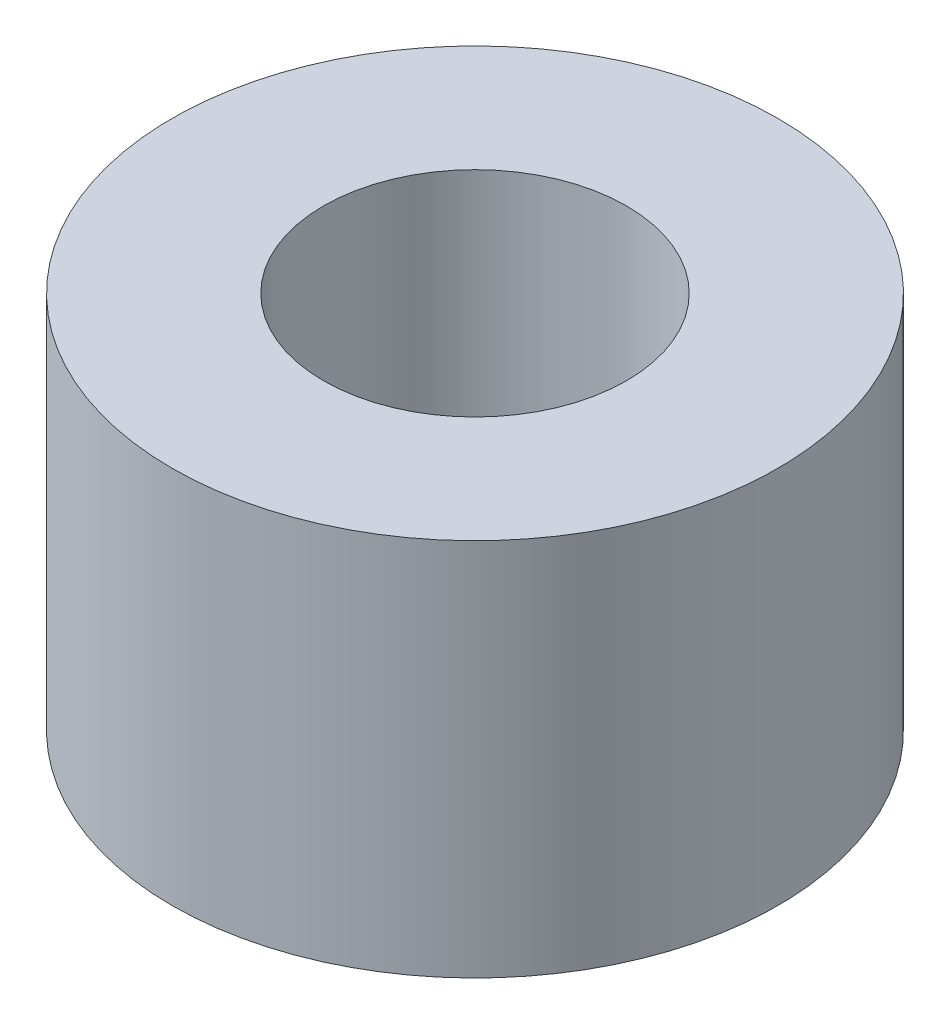
from build123d import *

# Parameters (mm, degrees)
SKETCH1_R           = 4
SKETCH1_R_2         = 2
BOSS_EXTRUDE1_DEPTH = 5


with BuildPart() as part:
    # Sketch1 → Boss-Extrude1 (new body)
    with BuildSketch(Plane(origin=(0, 0, 0), x_dir=(1, 0, 0), z_dir=(0, 1, 0))):
        Circle(SKETCH1_R)
        Circle(SKETCH1_R_2, mode=Mode.SUBTRACT)
    extrude(amount=BOSS_EXTRUDE1_DEPTH)


solid = part.part
